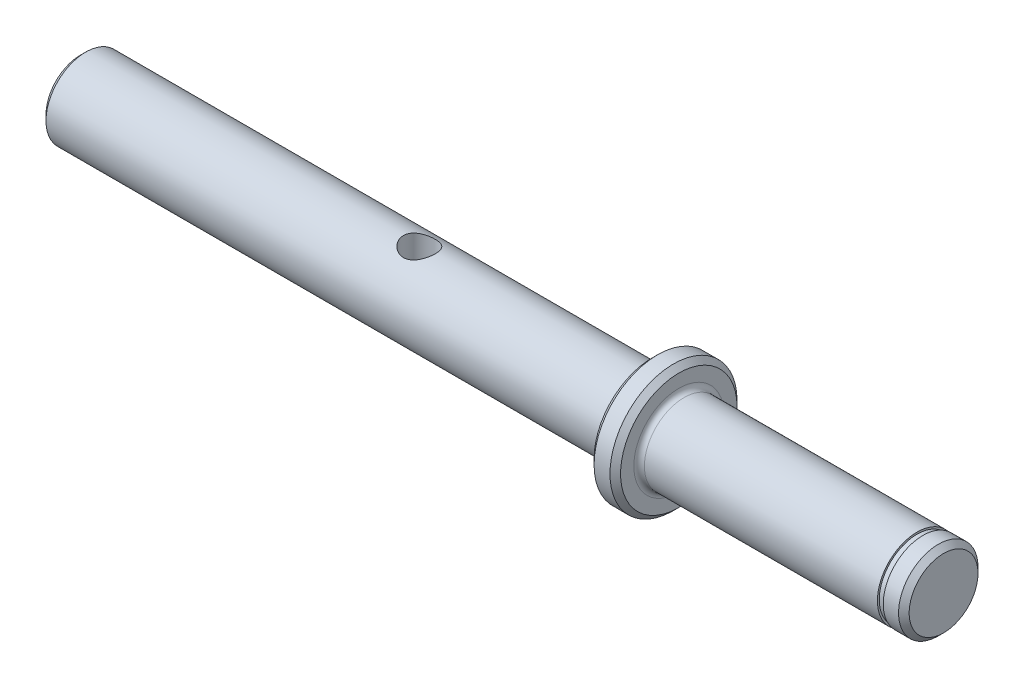
from build123d import *

# Parameters (mm, degrees)
CUT_EXTRUDE1_DEPTH      = 10
CUT_EXTRUDE1_DEPTH_BACK = 10
SKETCH2_R               = 3
CHAMFER1_SIZE           = 1
FILLET1_R               = 2
FILLET2_R               = 1


with BuildPart() as part:
    # Sketch1 → Revolve1 (revolve)
    with BuildSketch(Plane.XY):
        Polygon((0, 0), (0, 7.5), (108, 7.5), (108, 12), (113, 12), (113, 7.5), (158, 7.5), (158, 7.15), (159.1, 7.15), (159.1, 7.5), (163, 7.5), (163, 0), align=None)
    revolve(axis=Axis((0, 0, 0), (-1, 0, 0)))

    # Sketch2 → Cut-Extrude1 (cut, two sides: drawn at the far end of the back side and taken through both)
    with BuildSketch(Plane(origin=(0, 0, 0), x_dir=(1, 0, 0), z_dir=(0, 1, 0)).offset(-CUT_EXTRUDE1_DEPTH_BACK)):
        with Locations((64, 0)):
            Circle(SKETCH2_R)
    extrude(amount=CUT_EXTRUDE1_DEPTH + CUT_EXTRUDE1_DEPTH_BACK, mode=Mode.SUBTRACT)

    # Chamfer1
    chamfer1_edges = [part.edges().sort_by_distance(p)[0] for p in [
        (113, -12, 0),
        (108, -12, 0),
        (0, -7.5, 0),
        (163, -7.5, 0),
    ]]
    chamfer(chamfer1_edges, length=CHAMFER1_SIZE)

    # Fillet1
    fillet1_edges = [part.edges().sort_by_distance(p)[0] for p in [
        (108, -7.5, 0),
    ]]
    fillet(fillet1_edges, radius=FILLET1_R)

    # Fillet2
    fillet2_edges = [part.edges().sort_by_distance(p)[0] for p in [
        (113, -7.5, 0),
    ]]
    fillet(fillet2_edges, radius=FILLET2_R)


solid = part.part
